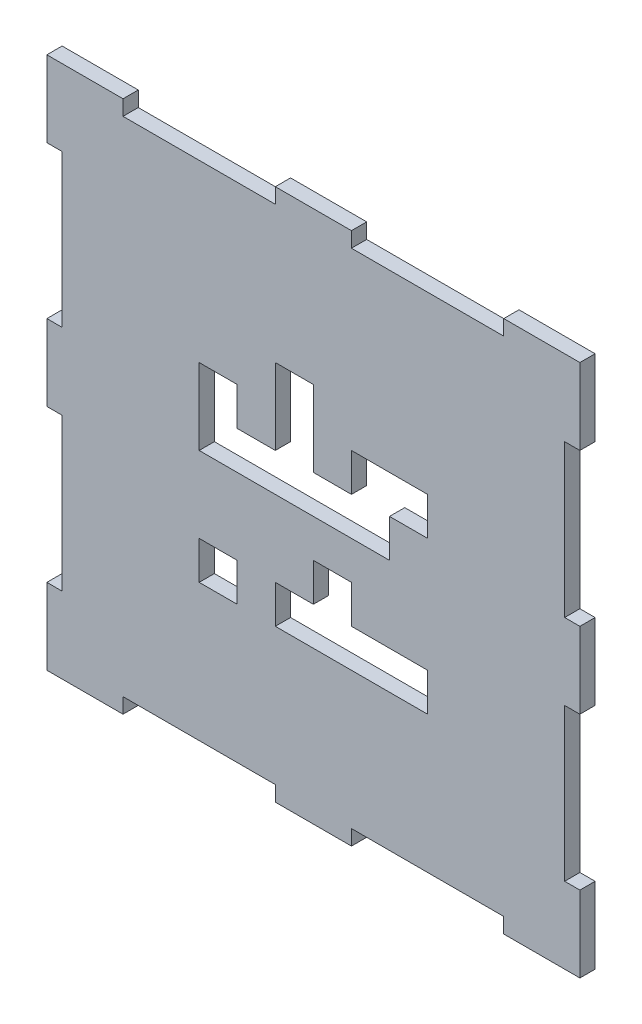
from build123d import *

# Parameters (mm, degrees)
SKETCH1_W           = 70
SKETCH1_H           = 70
BOSS_EXTRUDE1_DEPTH = 2
SKETCH2_W           = 2
SKETCH2_H           = 20
SKETCH2_W_2         = 20
SKETCH2_H_2         = 2
CUT_EXTRUDE1_DEPTH  = 2
SKETCH3_W           = 5
SKETCH3_H           = 5
CUT_EXTRUDE5_DEPTH  = 10


with BuildPart() as part:
    # Sketch1 → Boss-Extrude1 (new body)
    with BuildSketch(Plane.XY):
        Rectangle(SKETCH1_W, SKETCH1_H)
    extrude(amount=-BOSS_EXTRUDE1_DEPTH)

    # Sketch2 → Cut-Extrude1 (cut)
    with BuildSketch(Plane.XY):
        with Locations((-34, 15)):
            Rectangle(SKETCH2_W, SKETCH2_H)
        with Locations((-34, -15)):
            Rectangle(SKETCH2_W, SKETCH2_H)
        with Locations((-15, -34)):
            Rectangle(SKETCH2_W_2, SKETCH2_H_2)
        with Locations((15, -34)):
            Rectangle(SKETCH2_W_2, SKETCH2_H_2)
        with Locations((34, -15)):
            Rectangle(SKETCH2_W, SKETCH2_H)
        with Locations((34, 15)):
            Rectangle(SKETCH2_W, SKETCH2_H)
        with Locations((15, 34)):
            Rectangle(SKETCH2_W_2, SKETCH2_H_2)
        with Locations((-15, 34)):
            Rectangle(SKETCH2_W_2, SKETCH2_H_2)
    extrude(amount=-CUT_EXTRUDE1_DEPTH, mode=Mode.SUBTRACT)

    # Sketch3 → Cut-Extrude5 (cut)
    with BuildSketch(Plane.XY):
        with Locations((-12.5, 7.5)):
            Rectangle(SKETCH3_W, SKETCH3_H)
        with Locations((-12.5, 2.5)):
            Rectangle(SKETCH3_W, SKETCH3_H)
        with Locations((-7.5, 2.5)):
            Rectangle(SKETCH3_W, SKETCH3_H)
        with Locations((-2.5, 2.5)):
            Rectangle(SKETCH3_W, SKETCH3_H)
        with Locations((2.5, 2.5)):
            Rectangle(SKETCH3_W, SKETCH3_H)
        with Locations((7.5, 2.5)):
            Rectangle(SKETCH3_W, SKETCH3_H)
        with Locations((7.5, 7.5)):
            Rectangle(SKETCH3_W, SKETCH3_H)
        with Locations((12.5, 7.5)):
            Rectangle(SKETCH3_W, SKETCH3_H)
        with Locations((-2.5, 7.5)):
            Rectangle(SKETCH3_W, SKETCH3_H)
        with Locations((-2.5, 12.5)):
            Rectangle(SKETCH3_W, SKETCH3_H)
        with Locations((-12.5, -12.5)):
            Rectangle(SKETCH3_W, SKETCH3_H)
        with Locations((-2.5, -12.5)):
            Rectangle(SKETCH3_W, SKETCH3_H)
        with Locations((2.5, -12.5)):
            Rectangle(SKETCH3_W, SKETCH3_H)
        with Locations((7.5, -12.5)):
            Rectangle(SKETCH3_W, SKETCH3_H)
        with Locations((12.5, -12.5)):
            Rectangle(SKETCH3_W, SKETCH3_H)
        with Locations((2.5, -7.5)):
            Rectangle(SKETCH3_W, SKETCH3_H)
    extrude(amount=-CUT_EXTRUDE5_DEPTH, mode=Mode.SUBTRACT)


solid = part.part
